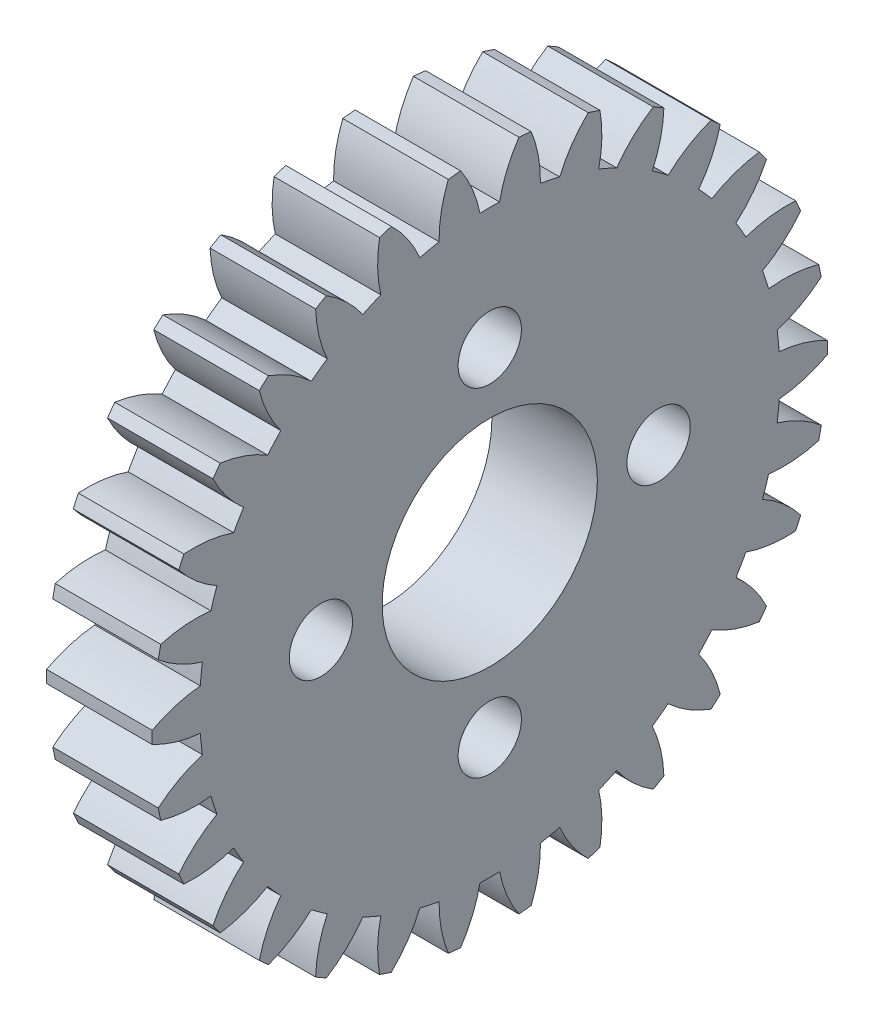
from build123d import *

# Parameters (mm, degrees)
BASPROSKE_W        = 10
BASPROSKE_H        = 16
TOOTHCUT_DEPTH     = 25.738633754
TEETHCUTS_COUNT    = 30
TEETHCUTS_ANGLE    = 348
HUBNEAONESKE_R     = 12.5
HUBNEARONE_DEPTH   = 8.0000508
BORSKE_R           = 3
BORE_DEPTH         = 18.0000508
SKETCH2_R          = 12.5
CUT_EXTRUDE1_DEPTH = 8.0000508
SKETCH3_R          = 5.1
CUT_EXTRUDE2_DEPTH = 10
SKETCH4_R          = 1.5
CUT_EXTRUDE3_DEPTH = 10
CUT_EXTRUDE4_DEPTH = 5


with BuildPart() as part:
    # BasProSke → Base-Revolve (revolve)
    with BuildSketch(Plane(origin=(0, 0, 0), x_dir=(1, 0, 0), z_dir=(0, 1, 0)), mode=Mode.PRIVATE) as base_revolve_sk:
        with Locations((5, 8)):
            Rectangle(BASPROSKE_W, BASPROSKE_H)
    revolve(base_revolve_sk.sketch.rotate(Axis((-10, 0, 0), (1, 0, 0)), 180), axis=Axis((-10, 0, 0), (1, 0, 0)))

    # TooCutSke → ToothCut (cut, through all)
    with BuildSketch(Plane(origin=(0, 0, 0), x_dir=(0, 0, -1), z_dir=(1, 0, 0))):
        with BuildLine():
            ThreePointArc((0.466400716, 13.741086979), (0, 13.749), (-0.466400716, 13.741086979))
            ThreePointArc((-0.466400716, 13.741086979), (-0.819142092, 14.899954875), (-1.3974676, 15.964351834))
            ThreePointArc((-1.3974676, 15.964351834), (0, 16.0254), (1.3974676, 15.964351834))
            ThreePointArc((1.3974676, 15.964351834), (0.819142092, 14.899954875), (0.466400716, 13.741086979))
        make_face()
    toothcut = extrude(amount=TOOTHCUT_DEPTH, mode=Mode.SUBTRACT)

    # TeethCuts: ToothCut ×30 about axis
    teethcuts_axis = Axis((-10, 0, 0), (1, 0, 0))
    for i in range(1, TEETHCUTS_COUNT):
        add(toothcut.rotate(teethcuts_axis, i * TEETHCUTS_ANGLE / (TEETHCUTS_COUNT - 1)), mode=Mode.SUBTRACT)

    # HubNeaOneSke → HubNearOne (add)
    with BuildSketch(Plane.ZY):
        with Locations(Location((0, 0, 0), (0, 0, 180))):
            Circle(HUBNEAONESKE_R)
    extrude(amount=HUBNEARONE_DEPTH)

    # BorSke → Bore (cut, symmetric)
    with BuildSketch(Plane(origin=(0, 0, 0), x_dir=(0, 0, -1), z_dir=(1, 0, 0))):
        with Locations(Location((0, 0, 0), (0, 0, 180))):
            Circle(BORSKE_R)
    extrude(amount=BORE_DEPTH, both=True, mode=Mode.SUBTRACT)

    # Sketch2 → Cut-Extrude1 (cut)
    with BuildSketch(Plane.ZY.offset(8.0000508)):
        Circle(SKETCH2_R)
    extrude(amount=-CUT_EXTRUDE1_DEPTH, mode=Mode.SUBTRACT)

    # Sketch3 → Cut-Extrude2 (cut)
    with BuildSketch(Plane(origin=(10, 0, 0), x_dir=(0, 0, -1), z_dir=(1, 0, 0))):
        Circle(SKETCH3_R)
    extrude(amount=-CUT_EXTRUDE2_DEPTH, mode=Mode.SUBTRACT)

    # Sketch4 → Cut-Extrude3 (cut)
    with BuildSketch(Plane.ZY):
        with Locations((0, -8)):
            Circle(SKETCH4_R)
        with Locations((-8, 0)):
            Circle(SKETCH4_R)
        with Locations((0, 8)):
            Circle(SKETCH4_R)
        with Locations((8, 0)):
            Circle(SKETCH4_R)
    extrude(amount=-CUT_EXTRUDE3_DEPTH, mode=Mode.SUBTRACT)

    # Sketch5 → Cut-Extrude4 (cut)
    with BuildSketch(Plane.ZY):
        with BuildLine():
            ThreePointArc((13.714564017, -0.972488982), (14.890017219, -0.746983902), (15.997323333, -0.292653692))
            ThreePointArc((15.997323333, -0.292653692), (16, 0), (15.997323333, 0.292653692))
            ThreePointArc((15.997323333, 0.292653692), (14.890017219, 0.746983902), (13.714564017, 0.972488982))
            ThreePointArc((13.714564017, 0.972488982), (13.673681539, 1.437161841), (13.617059717, 1.900180429))
            ThreePointArc((13.617059717, 1.900180429), (14.719941304, 2.365148144), (15.70858956, 3.039772036))
            ThreePointArc((15.70858956, 3.039772036), (15.650361612, 3.326587053), (15.586897312, 3.612289049))
            ThreePointArc((15.586897312, 3.612289049), (14.409327931, 3.826469168), (13.21267606, 3.802655958))
            ThreePointArc((13.21267606, 3.802655958), (13.076076043, 4.248674656), (12.924424565, 4.689802838))
            ThreePointArc((12.924424565, 4.689802838), (13.90653332, 5.373911868), (14.733315045, 6.23934514))
            ThreePointArc((14.733315045, 6.23934514), (14.616727322, 6.507786289), (14.495249085, 6.774050041))
            ThreePointArc((14.495249085, 6.774050041), (13.29888187, 6.73871937), (12.133330757, 6.466628622))
            ThreePointArc((12.133330757, 6.466628622), (11.906983277, 6.8745), (11.666930042, 7.274458358))
            ThreePointArc((11.666930042, 7.274458358), (12.485343098, 8.147809856), (13.114123965, 9.166228921))
            ThreePointArc((13.114123965, 9.166228921), (12.94427191, 9.404564037), (12.770088917, 9.639752541))
            ThreePointArc((12.770088917, 9.639752541), (11.607210855, 9.356455199), (10.523700679, 8.847978584))
            ThreePointArc((10.523700679, 8.847978584), (10.217498205, 9.199876707), (9.899534691, 9.541185141))
            ThreePointArc((9.899534691, 9.541185141), (10.518483472, 10.565609456), (10.921782738, 11.692504514))
            ThreePointArc((10.921782738, 11.692504514), (10.706089702, 11.890317208), (10.486814585, 12.084151598))
            ThreePointArc((10.486814585, 12.084151598), (9.408249029, 11.565269039), (8.454134382, 10.842629425))
            ThreePointArc((8.454134382, 10.842629425), (8.081459434, 11.123174656), (7.699482172, 11.39091635))
            ThreePointArc((7.699482172, 11.39091635), (8.091915645, 12.521641223), (8.252107198, 13.707761553))
            ThreePointArc((8.252107198, 13.707761553), (8, 13.856406461), (7.745216135, 14.000415245))
            ThreePointArc((7.745216135, 14.000415245), (6.798101574, 13.268625126), (6.015081845, 12.363405332))
            ThreePointArc((6.015081845, 12.363405332), (5.592222106, 12.560336497), (5.162925335, 12.742809854))
            ThreePointArc((5.162925335, 12.742809854), (5.311692275, 13.930417183), (5.221774975, 15.123923635))
            ThreePointArc((5.221774975, 15.123923635), (4.94427191, 15.216904261), (4.665114574, 15.304793563))
            ThreePointArc((4.665114574, 15.304793563), (3.890844459, 14.392078624), (3.313141369, 13.343841099))
            ThreePointArc((3.313141369, 13.343841099), (2.858577837, 13.448551362), (2.400723887, 13.537781422))
            ThreePointArc((2.400723887, 13.537781422), (2.299322464, 14.730367067), (1.963226128, 15.879097681))
            ThreePointArc((1.963226128, 15.879097681), (1.672455412, 15.912350326), (1.38112512, 15.940278962))
            ThreePointArc((1.38112512, 15.940278962), (0.813538771, 14.886529226), (0.466400716, 13.741086979))
            ThreePointArc((0.466400716, 13.741086979), (0, 13.749), (-0.466400716, 13.741086979))
            ThreePointArc((-0.466400716, 13.741086979), (-0.813538771, 14.886529226), (-1.38112512, 15.940278962))
            ThreePointArc((-1.38112512, 15.940278962), (-1.672455412, 15.912350326), (-1.963226128, 15.879097681))
            ThreePointArc((-1.963226128, 15.879097681), (-2.299322464, 14.730367067), (-2.400723887, 13.537781422))
            ThreePointArc((-2.400723887, 13.537781422), (-2.858577837, 13.448551362), (-3.313141369, 13.343841099))
            ThreePointArc((-3.313141369, 13.343841099), (-3.890844459, 14.392078624), (-4.665114574, 15.304793563))
            ThreePointArc((-4.665114574, 15.304793563), (-4.94427191, 15.216904261), (-5.221774975, 15.123923635))
            ThreePointArc((-5.221774975, 15.123923635), (-5.311692275, 13.930417183), (-5.162925335, 12.742809854))
            ThreePointArc((-5.162925335, 12.742809854), (-5.592222106, 12.560336497), (-6.015081845, 12.363405332))
            ThreePointArc((-6.015081845, 12.363405332), (-6.798101574, 13.268625126), (-7.745216135, 14.000415245))
            ThreePointArc((-7.745216135, 14.000415245), (-8, 13.856406461), (-8.252107198, 13.707761553))
            ThreePointArc((-8.252107198, 13.707761553), (-8.091915645, 12.521641223), (-7.699482172, 11.39091635))
            ThreePointArc((-7.699482172, 11.39091635), (-8.081459434, 11.123174656), (-8.454134382, 10.842629425))
            ThreePointArc((-8.454134382, 10.842629425), (-9.408249029, 11.565269039), (-10.486814585, 12.084151598))
            ThreePointArc((-10.486814585, 12.084151598), (-10.706089702, 11.890317208), (-10.921782738, 11.692504514))
            ThreePointArc((-10.921782738, 11.692504514), (-10.518483472, 10.565609456), (-9.899534691, 9.541185141))
            ThreePointArc((-9.899534691, 9.541185141), (-10.217498205, 9.199876707), (-10.523700679, 8.847978584))
            ThreePointArc((-10.523700679, 8.847978584), (-11.607210855, 9.356455199), (-12.770088917, 9.639752541))
            ThreePointArc((-12.770088917, 9.639752541), (-12.94427191, 9.404564037), (-13.114123965, 9.166228921))
            ThreePointArc((-13.114123965, 9.166228921), (-12.485343098, 8.147809856), (-11.666930042, 7.274458358))
            ThreePointArc((-11.666930042, 7.274458358), (-11.906983277, 6.8745), (-12.133330757, 6.466628622))
            ThreePointArc((-12.133330757, 6.466628622), (-13.29888187, 6.73871937), (-14.495249085, 6.774050041))
            ThreePointArc((-14.495249085, 6.774050041), (-14.616727322, 6.507786289), (-14.733315045, 6.23934514))
            ThreePointArc((-14.733315045, 6.23934514), (-13.90653332, 5.373911868), (-12.924424565, 4.689802838))
            ThreePointArc((-12.924424565, 4.689802838), (-13.076076043, 4.248674656), (-13.21267606, 3.802655958))
            ThreePointArc((-13.21267606, 3.802655958), (-14.409327931, 3.826469168), (-15.586897312, 3.612289049))
            ThreePointArc((-15.586897312, 3.612289049), (-15.650361612, 3.326587053), (-15.70858956, 3.039772036))
            ThreePointArc((-15.70858956, 3.039772036), (-14.719941304, 2.365148144), (-13.617059717, 1.900180429))
            ThreePointArc((-13.617059717, 1.900180429), (-13.673681539, 1.437161841), (-13.714564017, 0.972488982))
            ThreePointArc((-13.714564017, 0.972488982), (-14.890017219, 0.746983902), (-15.997323333, 0.292653692))
            ThreePointArc((-15.997323333, 0.292653692), (-16, 0), (-15.997323333, -0.292653692))
            ThreePointArc((-15.997323333, -0.292653692), (-14.890017219, -0.746983902), (-13.714564017, -0.972488982))
            ThreePointArc((-13.714564017, -0.972488982), (-13.673681539, -1.437161841), (-13.617059717, -1.900180429))
            ThreePointArc((-13.617059717, -1.900180429), (-14.719941304, -2.365148144), (-15.70858956, -3.039772036))
            ThreePointArc((-15.70858956, -3.039772036), (-15.650361612, -3.326587053), (-15.586897312, -3.612289049))
            ThreePointArc((-15.586897312, -3.612289049), (-14.409327931, -3.826469168), (-13.21267606, -3.802655958))
            ThreePointArc((-13.21267606, -3.802655958), (-13.076076043, -4.248674656), (-12.924424565, -4.689802838))
            ThreePointArc((-12.924424565, -4.689802838), (-13.90653332, -5.373911868), (-14.733315045, -6.23934514))
            ThreePointArc((-14.733315045, -6.23934514), (-14.616727322, -6.507786289), (-14.495249085, -6.774050041))
            ThreePointArc((-14.495249085, -6.774050041), (-13.29888187, -6.73871937), (-12.133330757, -6.466628622))
            ThreePointArc((-12.133330757, -6.466628622), (-11.906983277, -6.8745), (-11.666930042, -7.274458358))
            ThreePointArc((-11.666930042, -7.274458358), (-12.485343098, -8.147809856), (-13.114123965, -9.166228921))
            ThreePointArc((-13.114123965, -9.166228921), (-12.94427191, -9.404564037), (-12.770088917, -9.639752541))
            ThreePointArc((-12.770088917, -9.639752541), (-11.607210855, -9.356455199), (-10.523700679, -8.847978584))
            ThreePointArc((-10.523700679, -8.847978584), (-10.217498205, -9.199876707), (-9.899534691, -9.541185141))
            ThreePointArc((-9.899534691, -9.541185141), (-10.518483472, -10.565609456), (-10.921782738, -11.692504514))
            ThreePointArc((-10.921782738, -11.692504514), (-10.706089702, -11.890317208), (-10.486814585, -12.084151598))
            ThreePointArc((-10.486814585, -12.084151598), (-9.408249029, -11.565269039), (-8.454134382, -10.842629425))
            ThreePointArc((-8.454134382, -10.842629425), (-8.081459434, -11.123174656), (-7.699482172, -11.39091635))
            ThreePointArc((-7.699482172, -11.39091635), (-8.091915645, -12.521641223), (-8.252107198, -13.707761553))
            ThreePointArc((-8.252107198, -13.707761553), (-8, -13.856406461), (-7.745216135, -14.000415245))
            ThreePointArc((-7.745216135, -14.000415245), (-6.798101574, -13.268625126), (-6.015081845, -12.363405332))
            ThreePointArc((-6.015081845, -12.363405332), (-5.592222106, -12.560336497), (-5.162925335, -12.742809854))
            ThreePointArc((-5.162925335, -12.742809854), (-5.311692275, -13.930417183), (-5.221774975, -15.123923635))
            ThreePointArc((-5.221774975, -15.123923635), (-4.94427191, -15.216904261), (-4.665114574, -15.304793563))
            ThreePointArc((-4.665114574, -15.304793563), (-3.890844459, -14.392078624), (-3.313141369, -13.343841099))
            ThreePointArc((-3.313141369, -13.343841099), (-2.858577837, -13.448551362), (-2.400723887, -13.537781422))
            ThreePointArc((-2.400723887, -13.537781422), (-2.299322464, -14.730367067), (-1.963226128, -15.879097681))
            ThreePointArc((-1.963226128, -15.879097681), (-1.672455412, -15.912350326), (-1.38112512, -15.940278962))
            ThreePointArc((-1.38112512, -15.940278962), (-0.813538771, -14.886529226), (-0.466400716, -13.741086979))
            ThreePointArc((-0.466400716, -13.741086979), (0, -13.749), (0.466400716, -13.741086979))
            ThreePointArc((0.466400716, -13.741086979), (0.813538771, -14.886529226), (1.38112512, -15.940278962))
            ThreePointArc((1.38112512, -15.940278962), (1.672455412, -15.912350326), (1.963226128, -15.879097681))
            ThreePointArc((1.963226128, -15.879097681), (2.299322464, -14.730367067), (2.400723887, -13.537781422))
            ThreePointArc((2.400723887, -13.537781422), (2.858577837, -13.448551362), (3.313141369, -13.343841099))
            ThreePointArc((3.313141369, -13.343841099), (3.890844459, -14.392078624), (4.665114574, -15.304793563))
            ThreePointArc((4.665114574, -15.304793563), (4.94427191, -15.216904261), (5.221774975, -15.123923635))
            ThreePointArc((5.221774975, -15.123923635), (5.311692275, -13.930417183), (5.162925335, -12.742809854))
            ThreePointArc((5.162925335, -12.742809854), (5.592222106, -12.560336497), (6.015081845, -12.363405332))
            ThreePointArc((6.015081845, -12.363405332), (6.798101574, -13.268625126), (7.745216135, -14.000415245))
            ThreePointArc((7.745216135, -14.000415245), (8, -13.856406461), (8.252107198, -13.707761553))
            ThreePointArc((8.252107198, -13.707761553), (8.091915645, -12.521641223), (7.699482172, -11.39091635))
            ThreePointArc((7.699482172, -11.39091635), (8.081459434, -11.123174656), (8.454134382, -10.842629425))
            ThreePointArc((8.454134382, -10.842629425), (9.408249029, -11.565269039), (10.486814585, -12.084151598))
            ThreePointArc((10.486814585, -12.084151598), (10.706089702, -11.890317208), (10.921782738, -11.692504514))
            ThreePointArc((10.921782738, -11.692504514), (10.518483472, -10.565609456), (9.899534691, -9.541185141))
            ThreePointArc((9.899534691, -9.541185141), (10.217498205, -9.199876707), (10.523700679, -8.847978584))
            ThreePointArc((10.523700679, -8.847978584), (11.607210855, -9.356455199), (12.770088917, -9.639752541))
            ThreePointArc((12.770088917, -9.639752541), (12.94427191, -9.404564037), (13.114123965, -9.166228921))
            ThreePointArc((13.114123965, -9.166228921), (12.485343098, -8.147809856), (11.666930042, -7.274458358))
            ThreePointArc((11.666930042, -7.274458358), (11.906983277, -6.8745), (12.133330757, -6.466628622))
            ThreePointArc((12.133330757, -6.466628622), (13.29888187, -6.73871937), (14.495249085, -6.774050041))
            ThreePointArc((14.495249085, -6.774050041), (14.616727322, -6.507786289), (14.733315045, -6.23934514))
            ThreePointArc((14.733315045, -6.23934514), (13.90653332, -5.373911868), (12.924424565, -4.689802838))
            ThreePointArc((12.924424565, -4.689802838), (13.076076043, -4.248674656), (13.21267606, -3.802655958))
            ThreePointArc((13.21267606, -3.802655958), (14.409327931, -3.826469168), (15.586897312, -3.612289049))
            ThreePointArc((15.586897312, -3.612289049), (15.650361612, -3.326587053), (15.70858956, -3.039772036))
            ThreePointArc((15.70858956, -3.039772036), (14.719941304, -2.365148144), (13.617059717, -1.900180429))
            ThreePointArc((13.617059717, -1.900180429), (13.673681539, -1.437161841), (13.714564017, -0.972488982))
        make_face()
    extrude(amount=-CUT_EXTRUDE4_DEPTH, mode=Mode.SUBTRACT)


solid = part.part
